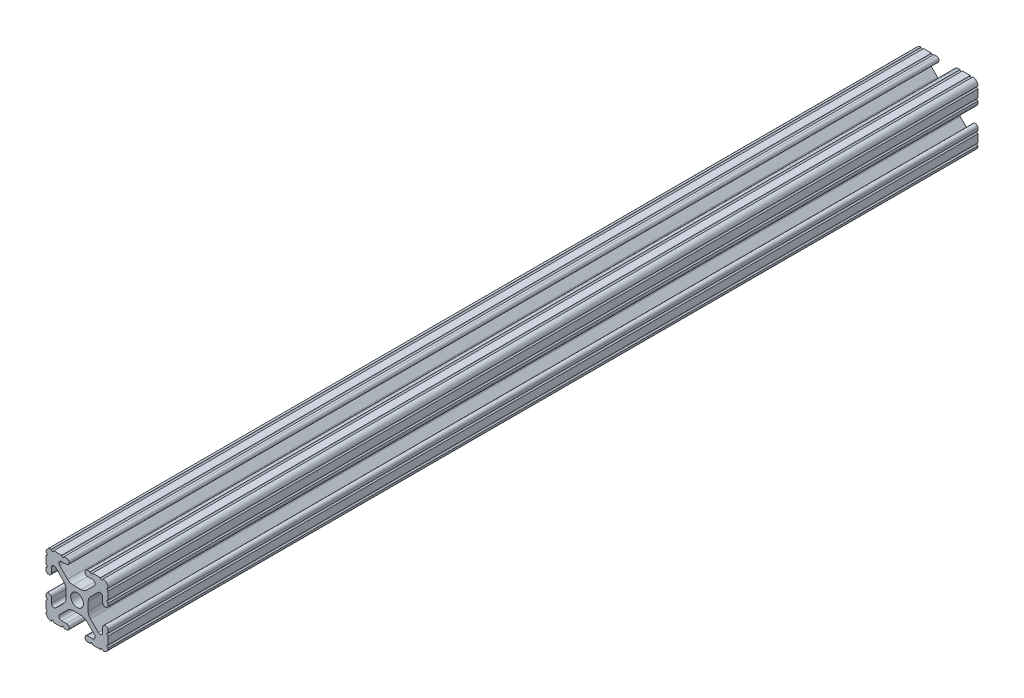
from build123d import *

# Parameters (mm, degrees)
SKETCH11_R              = 2.6035
FRACTIONAL_1010_1_DEPTH = 355.6


with BuildPart() as part:
    # Sketch11 → Fractional 1010(1) (new body)
    with BuildSketch(Plane(origin=(0, 0, 0), x_dir=(0, -1, 0), z_dir=(0, 0, 1))):
        with BuildLine():
            Line((10.5918, 12.7), (10.5664, 12.7))
            ThreePointArc((10.5664, 12.7), (10.0584, 12.192), (9.5504, 12.7))
            Line((9.5504, 12.7), (6.3246, 12.7))
            ThreePointArc((6.3246, 12.7), (5.8166, 12.192), (5.3086, 12.7))
            Line((5.3086, 12.7), (4.3561, 12.7))
            ThreePointArc((4.3561, 12.7), (3.2512, 11.5951), (4.3561, 10.4902))
            Line((4.3561, 10.4902), (6.370083786, 10.4902))
            ThreePointArc((6.370083786, 10.4902), (7.348856743, 9.836204819), (7.119204175, 8.681663397))
            Line((7.119204175, 8.681663397), (3.88464389, 5.447103113))
            ThreePointArc((3.88464389, 5.447103113), (2.854599758, 4.758849627), (1.63957986, 4.517167143))
            Line((1.63957986, 4.517167143), (-1.63957986, 4.517167143))
            ThreePointArc((-1.63957986, 4.517167143), (-2.854599758, 4.758849627), (-3.88464389, 5.447103113))
            Line((-3.88464389, 5.447103113), (-7.119204175, 8.681663397))
            ThreePointArc((-7.119204175, 8.681663397), (-7.348856743, 9.836204819), (-6.370083786, 10.4902))
            Line((-6.370083786, 10.4902), (-4.3561, 10.4902))
            ThreePointArc((-4.3561, 10.4902), (-3.2512, 11.5951), (-4.3561, 12.7))
            Line((-4.3561, 12.7), (-5.3086, 12.7))
            ThreePointArc((-5.3086, 12.7), (-5.8166, 12.192), (-6.3246, 12.7))
            Line((-6.3246, 12.7), (-9.5504, 12.7))
            ThreePointArc((-9.5504, 12.7), (-10.0584, 12.192), (-10.5664, 12.7))
            Line((-10.5664, 12.7), (-10.5918, 12.7))
            ThreePointArc((-10.5918, 12.7), (-12.082522516, 12.082522516), (-12.7, 10.5918))
            Line((-12.7, 10.5918), (-12.7, 10.5664))
            ThreePointArc((-12.7, 10.5664), (-12.192, 10.0584), (-12.7, 9.5504))
            Line((-12.7, 9.5504), (-12.7, 6.3246))
            ThreePointArc((-12.7, 6.3246), (-12.192, 5.8166), (-12.7, 5.3086))
            Line((-12.7, 5.3086), (-12.7, 4.3561))
            ThreePointArc((-12.7, 4.3561), (-11.5951, 3.2512), (-10.4902, 4.3561))
            Line((-10.4902, 4.3561), (-10.4902, 6.370083786))
            ThreePointArc((-10.4902, 6.370083786), (-9.836204819, 7.348856743), (-8.681663397, 7.119204175))
            Line((-8.681663397, 7.119204175), (-5.447103113, 3.88464389))
            ThreePointArc((-5.447103113, 3.88464389), (-4.758849627, 2.854599758), (-4.517167143, 1.63957986))
            Line((-4.517167143, 1.63957986), (-4.517167143, -1.63957986))
            ThreePointArc((-4.517167143, -1.63957986), (-4.758849627, -2.854599758), (-5.447103113, -3.88464389))
            Line((-5.447103113, -3.88464389), (-8.681663397, -7.119204175))
            ThreePointArc((-8.681663397, -7.119204175), (-9.836204819, -7.348856743), (-10.4902, -6.370083786))
            Line((-10.4902, -6.370083786), (-10.4902, -4.3561))
            ThreePointArc((-10.4902, -4.3561), (-11.5951, -3.2512), (-12.7, -4.3561))
            Line((-12.7, -4.3561), (-12.7, -5.3086))
            ThreePointArc((-12.7, -5.3086), (-12.192, -5.8166), (-12.7, -6.3246))
            Line((-12.7, -6.3246), (-12.7, -9.5504))
            ThreePointArc((-12.7, -9.5504), (-12.192, -10.0584), (-12.7, -10.5664))
            Line((-12.7, -10.5664), (-12.7, -10.5918))
            ThreePointArc((-12.7, -10.5918), (-12.082522516, -12.082522516), (-10.5918, -12.7))
            Line((-10.5918, -12.7), (-10.5664, -12.7))
            ThreePointArc((-10.5664, -12.7), (-10.0584, -12.192), (-9.5504, -12.7))
            Line((-9.5504, -12.7), (-6.3246, -12.7))
            ThreePointArc((-6.3246, -12.7), (-5.8166, -12.192), (-5.3086, -12.7))
            Line((-5.3086, -12.7), (-4.3561, -12.7))
            ThreePointArc((-4.3561, -12.7), (-3.2512, -11.5951), (-4.3561, -10.4902))
            Line((-4.3561, -10.4902), (-6.370083786, -10.4902))
            ThreePointArc((-6.370083786, -10.4902), (-7.348856743, -9.836204819), (-7.119204175, -8.681663397))
            Line((-7.119204175, -8.681663397), (-3.88464389, -5.447103113))
            ThreePointArc((-3.88464389, -5.447103113), (-2.854599758, -4.758849627), (-1.63957986, -4.517167143))
            Line((-1.63957986, -4.517167143), (1.63957986, -4.517167143))
            ThreePointArc((1.63957986, -4.517167143), (2.854599758, -4.758849627), (3.88464389, -5.447103113))
            Line((3.88464389, -5.447103113), (7.119204175, -8.681663397))
            ThreePointArc((7.119204175, -8.681663397), (7.348856743, -9.836204819), (6.370083786, -10.4902))
            Line((6.370083786, -10.4902), (4.3561, -10.4902))
            ThreePointArc((4.3561, -10.4902), (3.2512, -11.5951), (4.3561, -12.7))
            Line((4.3561, -12.7), (5.3086, -12.7))
            ThreePointArc((5.3086, -12.7), (5.8166, -12.192), (6.3246, -12.7))
            Line((6.3246, -12.7), (9.5504, -12.7))
            ThreePointArc((9.5504, -12.7), (10.0584, -12.192), (10.5664, -12.7))
            Line((10.5664, -12.7), (10.5918, -12.7))
            ThreePointArc((10.5918, -12.7), (12.082522516, -12.082522516), (12.7, -10.5918))
            Line((12.7, -10.5918), (12.7, -10.5664))
            ThreePointArc((12.7, -10.5664), (12.192, -10.0584), (12.7, -9.5504))
            Line((12.7, -9.5504), (12.7, -6.3246))
            ThreePointArc((12.7, -6.3246), (12.192, -5.8166), (12.7, -5.3086))
            Line((12.7, -5.3086), (12.7, -4.3561))
            ThreePointArc((12.7, -4.3561), (11.5951, -3.2512), (10.4902, -4.3561))
            Line((10.4902, -4.3561), (10.4902, -6.370083786))
            ThreePointArc((10.4902, -6.370083786), (9.836204819, -7.348856743), (8.681663397, -7.119204175))
            Line((8.681663397, -7.119204175), (5.447103113, -3.88464389))
            ThreePointArc((5.447103113, -3.88464389), (4.758849627, -2.854599758), (4.517167143, -1.63957986))
            Line((4.517167143, -1.63957986), (4.517167143, 1.63957986))
            ThreePointArc((4.517167143, 1.63957986), (4.758849627, 2.854599758), (5.447103113, 3.88464389))
            Line((5.447103113, 3.88464389), (8.681663397, 7.119204175))
            ThreePointArc((8.681663397, 7.119204175), (9.836204819, 7.348856743), (10.4902, 6.370083786))
            Line((10.4902, 6.370083786), (10.4902, 4.3561))
            ThreePointArc((10.4902, 4.3561), (11.5951, 3.2512), (12.7, 4.3561))
            Line((12.7, 4.3561), (12.7, 5.3086))
            ThreePointArc((12.7, 5.3086), (12.192, 5.8166), (12.7, 6.3246))
            Line((12.7, 6.3246), (12.7, 9.5504))
            ThreePointArc((12.7, 9.5504), (12.192, 10.0584), (12.7, 10.5664))
            Line((12.7, 10.5664), (12.7, 10.5918))
            ThreePointArc((12.7, 10.5918), (12.082522516, 12.082522516), (10.5918, 12.7))
        make_face()
        Circle(SKETCH11_R, mode=Mode.SUBTRACT)
    extrude(amount=FRACTIONAL_1010_1_DEPTH)


solid = part.part
